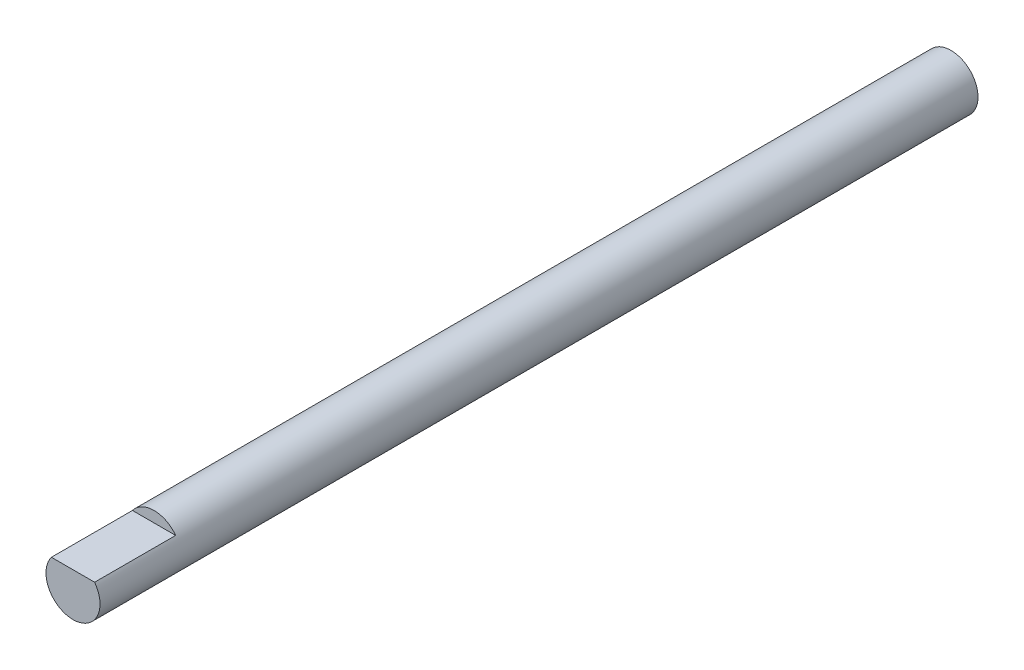
from build123d import *

# Parameters (mm, degrees)
CROQUIS1_R              = 4
SALIENTE_EXTRUIR1_DEPTH = 130
CORTAR_EXTRUIR1_DEPTH   = 12


with BuildPart() as part:
    # Croquis1 → Saliente-Extruir1 (new body)
    with BuildSketch(Plane.XY):
        Circle(CROQUIS1_R)
    extrude(amount=SALIENTE_EXTRUIR1_DEPTH)

    # Croquis2 → Cortar-Extruir1 (cut)
    with BuildSketch(Plane.XY.offset(130)):
        with BuildLine():
            Line((-3.2, 2.4), (3.2, 2.4))
            ThreePointArc((3.2, 2.4), (0, 4), (-3.2, 2.4))
        make_face()
    extrude(amount=-CORTAR_EXTRUIR1_DEPTH, mode=Mode.SUBTRACT)


solid = part.part
